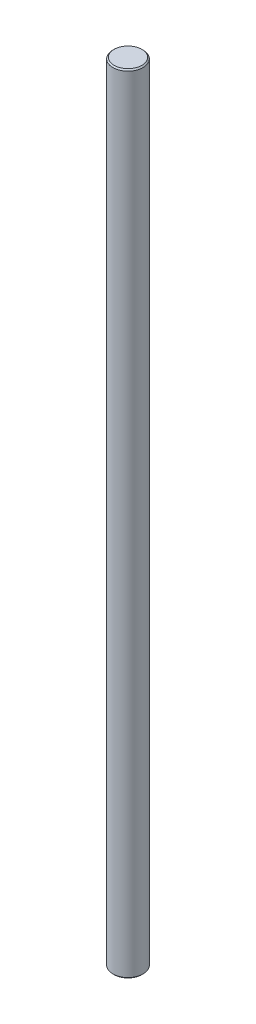
from build123d import *

# Parameters (mm, degrees)
CROQUIS1_R              = 6
SALIENTE_EXTRUIR1_DEPTH = 312
CHAFL_N1_SIZE           = 0.5


with BuildPart() as part:
    # Croquis1 → Saliente-Extruir1 (new body)
    with BuildSketch(Plane(origin=(0, 0, 0), x_dir=(1, 0, 0), z_dir=(0, 1, 0))):
        Circle(CROQUIS1_R)
    extrude(amount=SALIENTE_EXTRUIR1_DEPTH)

    # Chaflán1
    chafl_n1_edges = [part.edges().sort_by_distance(p)[0] for p in [
        (-6, 0, 0),
        (-6, 312, 0),
    ]]
    chamfer(chafl_n1_edges, length=CHAFL_N1_SIZE)


solid = part.part
